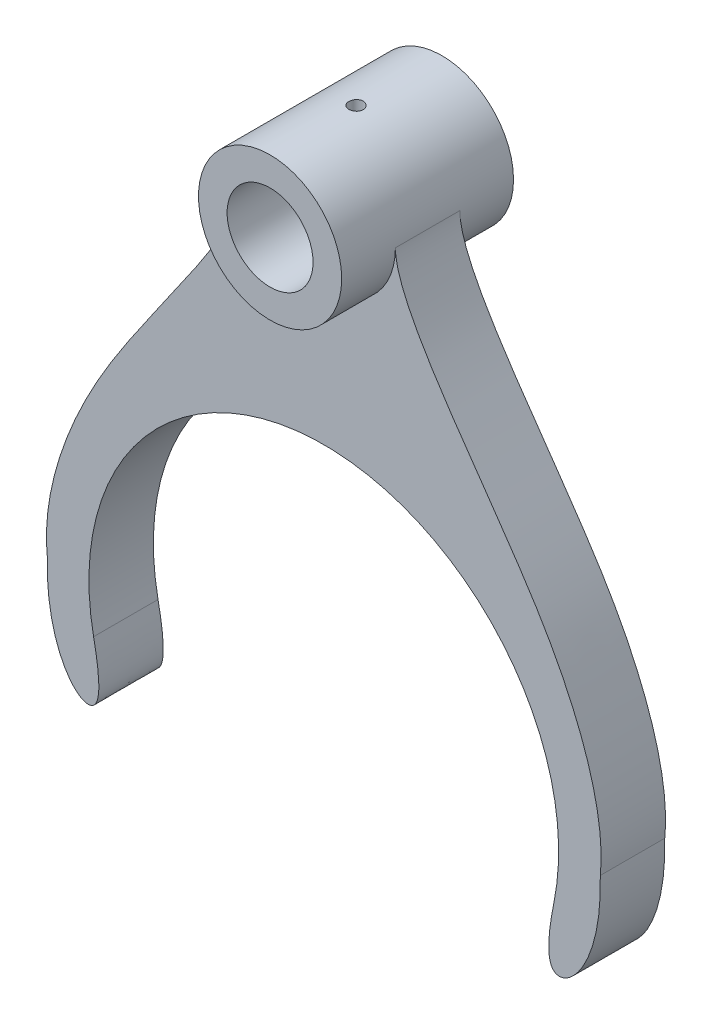
from build123d import *

# Parameters (mm, degrees)
BOSS_EXTRUDE1_DEPTH = 11.25
SKETCH1_3_R         = 25
SKETCH1_3_R_2       = 15
BOSS_EXTRUDE2_DEPTH = 30
CUT_EXTRUDE1_START  = -30
SKETCH3_R           = 2.5
CUT_EXTRUDE1_DEPTH  = 271.10596139


with BuildPart() as part:
    # Sketch1 → Boss-Extrude1 (new, symmetric)
    with BuildSketch(Plane.XY):
        with BuildLine():
            ThreePointArc((-80.369346148, -16.271699348), (0, 82), (80.369346148, -16.271699348))
            add(Edge.make_bspline(
                [(80.369346148, -16.271699348), (78.112479352, -27.418839229), (77.47349205, -47.573942744), (97.326558794, -29.331535138), (96.493331921, 1.730233625), (104.346209231, 42.222860352), (25, 135.629553039), (25, 154)],
                knots=[0, 0, 0, 0, 0.336275971, 1, 1, 1.039152319, 1.065410224, 1.065410224, 1.065410224, 1.065410224], degree=3))
            ThreePointArc((25, 154), (0, 129), (-25, 154))
            add(Edge.make_bspline(
                [(-25, 154), (-25, 135.629553039), (-104.346209231, 42.222860352), (-96.493331921, 1.730233625), (-97.326558794, -29.331535138), (-77.47349205, -47.573942744), (-78.112479352, -27.418839229), (-80.369346148, -16.271699348)],
                knots=[0, 0, 0, 0, 0.401434257, 1, 1, 11.147099128, 16.288129835, 16.288129835, 16.288129835, 16.288129835], degree=3))
        make_face()
    extrude(amount=BOSS_EXTRUDE1_DEPTH, both=True)

    # Sketch1_3 → Boss-Extrude2 (add, symmetric)
    with BuildSketch(Plane.XY):
        with Locations((0, 154)):
            Circle(SKETCH1_3_R)
        with Locations((0, 154)):
            Circle(SKETCH1_3_R_2, mode=Mode.SUBTRACT)
    extrude(amount=BOSS_EXTRUDE2_DEPTH, both=True)

    # Sketch3 → Cut-Extrude1 (cut, through all)
    with BuildSketch(Plane(origin=(0, 180, 0), x_dir=(1, 0, 0), z_dir=(0, 1, 0)).offset(CUT_EXTRUDE1_START)):
        Circle(SKETCH3_R)
    extrude(amount=CUT_EXTRUDE1_DEPTH, mode=Mode.SUBTRACT)


solid = part.part
